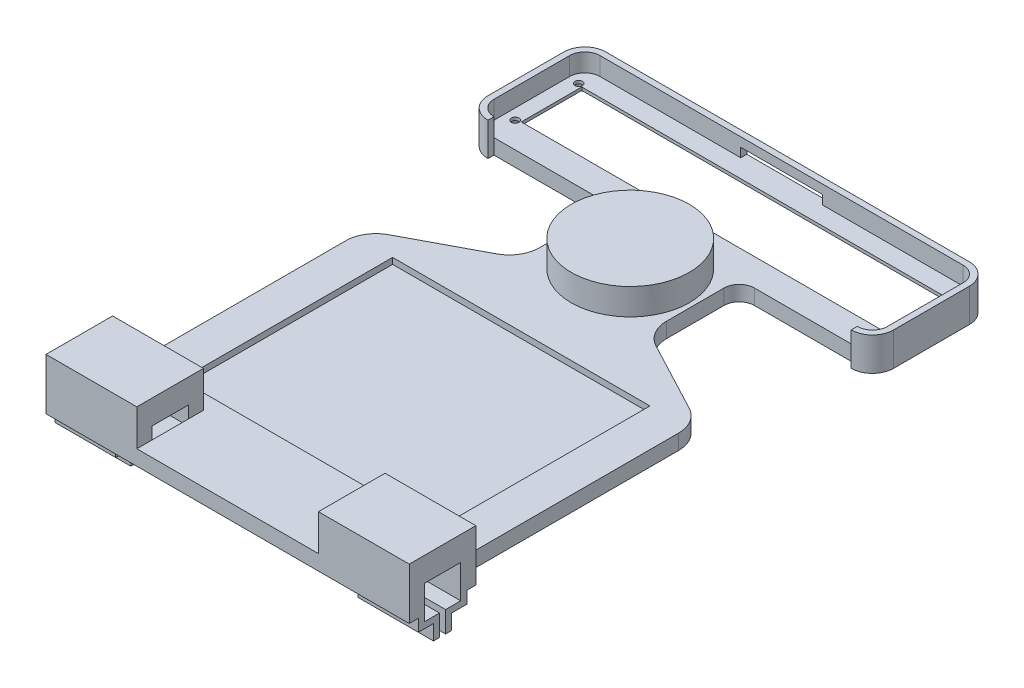
from build123d import *

# Parameters (mm, degrees)
BOSS_EXTRUDE1_DEPTH      = 2.5
SKETCH2_W                = 20
SKETCH2_H                = 12
CUT_EXTRUDE1_DEPTH       = 3
BOSS_EXTRUDE3_DEPTH      = 6
BOSS_EXTRUDE3_DEPTH_BACK = 5
BOSS_EXTRUDE4_DEPTH      = 20
BOSS_EXTRUDE5_DEPTH      = 20
SKETCH14_R               = 1.5
CUT_EXTRUDE6_DEPTH       = 178
SKETCH11_W               = 27
SKETCH11_H               = 3
CUT_EXTRUDE7_DEPTH       = 10
SKETCH15_R               = 1.25
SKETCH15_W               = 120
SKETCH15_H               = 20
CUT_EXTRUDE8_DEPTH       = 12
SKETCH15_3_R             = 1.25
SKETCH15_3_W             = 120
SKETCH15_3_H             = 20
CUT_EXTRUDE9_DEPTH       = 4
SKETCH17_W               = 30
SKETCH17_H               = 22
BOSS_EXTRUDE6_DEPTH      = 7
SKETCH18_W               = 12
SKETCH18_H               = 6
CUT_EXTRUDE11_DEPTH      = 30
SKETCH19_W               = 12
SKETCH19_H               = 6
CUT_EXTRUDE12_DEPTH      = 30
SKETCH16_W               = 85
SKETCH16_H               = 70
CUT_EXTRUDE13_DEPTH      = 2
SKETCH20_R               = 19.5
BOSS_EXTRUDE7_DEPTH      = 13.7
FILLET1_R                = 10
FILLET2_R                = 5
SKETCH21_W               = 30
SKETCH21_H               = 22
BOSS_EXTRUDE8_DEPTH      = 5


with BuildPart() as part:
    # Sketch1 → Boss-Extrude1 (new body, symmetric)
    with BuildSketch(Plane(origin=(0, 0, 0), x_dir=(1, 0, 0), z_dir=(0, 1, 0))):
        with BuildLine():
            Line((-21, 56.5), (-21, 26.5))
            Line((-21, 26.5), (-55, 8.5))
            Line((-55, 8.5), (-55, -69.5))
            Line((-55, -69.5), (-60, -69.5))
            Line((-60, -69.5), (-60, -91.5))
            Line((-60, -91.5), (60, -91.5))
            Line((60, -91.5), (60, -69.5))
            Line((60, -69.5), (55, -69.5))
            Line((55, -69.5), (55, 8.5))
            Line((55, 8.5), (21, 26.5))
            Line((21, 26.5), (21, 56.5))
            Line((21, 56.5), (60, 56.5))
            ThreePointArc((60, 56.5), (63.535533906, 57.964466094), (65, 61.5))
            Line((65, 61.5), (65, 86.5))
            ThreePointArc((65, 86.5), (63.535533906, 90.035533906), (60, 91.5))
            Line((60, 91.5), (-60, 91.5))
            ThreePointArc((-60, 91.5), (-63.535533906, 90.035533906), (-65, 86.5))
            Line((-65, 86.5), (-65, 61.5))
            ThreePointArc((-65, 61.5), (-63.535533906, 57.964466094), (-60, 56.5))
            Line((-60, 56.5), (-21, 56.5))
        make_face()
    extrude(amount=BOSS_EXTRUDE1_DEPTH, both=True)

    # Sketch2 → Cut-Extrude1 (cut)
    with BuildSketch(Plane.XZ.offset(2.5)):
        with Locations((-50, 80.5)):
            Rectangle(SKETCH2_W, SKETCH2_H)
        with Locations((50, 80.5)):
            Rectangle(SKETCH2_W, SKETCH2_H)
    extrude(amount=-CUT_EXTRUDE1_DEPTH, mode=Mode.SUBTRACT)

    # Sketch5 → Boss-Extrude3 (add, two sides)
    with BuildSketch(Plane(origin=(0, 2.5, 0), x_dir=(1, 0, 0), z_dir=(0, 1, 0))) as boss_extrude3_sk:
        with BuildLine():
            Line((-60, 56.5), (-60, 54.5))
            ThreePointArc((-60, 54.5), (-64.949747468, 56.550252532), (-67, 61.5))
            Line((-67, 61.5), (-67, 86.5))
            ThreePointArc((-67, 86.5), (-64.949747468, 91.449747468), (-60, 93.5))
            Line((-60, 93.5), (60, 93.5))
            ThreePointArc((60, 93.5), (64.949747468, 91.449747468), (67, 86.5))
            Line((67, 86.5), (67, 61.5))
            ThreePointArc((67, 61.5), (64.949747468, 56.550252532), (60, 54.5))
            Line((60, 54.5), (60, 56.5))
            ThreePointArc((60, 56.5), (63.535533906, 57.964466094), (65, 61.5))
            Line((65, 61.5), (65, 86.5))
            ThreePointArc((65, 86.5), (63.535533906, 90.035533906), (60, 91.5))
            Line((60, 91.5), (-60, 91.5))
            ThreePointArc((-60, 91.5), (-63.535533906, 90.035533906), (-65, 86.5))
            Line((-65, 86.5), (-65, 61.5))
            ThreePointArc((-65, 61.5), (-63.535533906, 57.964466094), (-60, 56.5))
        make_face()
    extrude(amount=BOSS_EXTRUDE3_DEPTH)
    extrude(boss_extrude3_sk.sketch, amount=-BOSS_EXTRUDE3_DEPTH_BACK)

    # Sketch12 → Boss-Extrude4 (add)
    with BuildSketch(Plane.ZY.offset(60)):
        Polygon((74.5, -2.5), (74.5, -4.5), (79.5, -4.5), (79.5, -11.5), (77.5, -11.5), (77.5, -6.5), (72.5, -6.5), (72.5, -4.5), (72.5, -2.5), align=None)
        Polygon((81.5, -11.5), (83.5, -11.5), (83.5, -6.5), (88.5, -6.5), (88.5, -4.5), (88.5, -2.5), (86.5, -2.5), (86.5, -4.5), (81.5, -4.5), align=None)
    extrude(amount=-BOSS_EXTRUDE4_DEPTH)

    # Sketch13 → Boss-Extrude5 (add)
    with BuildSketch(Plane(origin=(60, 0, 0), x_dir=(0, 0, -1), z_dir=(1, 0, 0))):
        Polygon((-86.5, -2.5), (-86.5, -4.5), (-81.5, -4.5), (-81.5, -11.5), (-83.5, -11.5), (-83.5, -6.5), (-88.5, -6.5), (-88.5, -2.5), align=None)
        Polygon((-79.5, -11.5), (-77.5, -11.5), (-77.5, -6.5), (-72.5, -6.5), (-72.5, -2.5), (-74.5, -2.5), (-74.5, -4.5), (-79.5, -4.5), align=None)
    extrude(amount=-BOSS_EXTRUDE5_DEPTH)

    # Sketch14 → Cut-Extrude6 (cut, through all)
    with BuildSketch(Plane.XY.offset(83.5)):
        with Locations((45, -8.5)):
            Circle(SKETCH14_R)
        with Locations((55, -8.5)):
            Circle(SKETCH14_R)
        with Locations((-55, -8.5)):
            Circle(SKETCH14_R)
        with Locations((-45, -8.5)):
            Circle(SKETCH14_R)
    extrude(amount=-CUT_EXTRUDE6_DEPTH, mode=Mode.SUBTRACT)

    # Sketch11 → Cut-Extrude7 (cut)
    with BuildSketch(Plane(origin=(0, 0, -93.5), x_dir=(-1, 0, 0), z_dir=(0, 0, -1))):
        with Locations((0, 4)):
            Rectangle(SKETCH11_W, SKETCH11_H)
    extrude(amount=-CUT_EXTRUDE7_DEPTH, mode=Mode.SUBTRACT)

    # Sketch15 → Cut-Extrude8 (cut, through all)
    with BuildSketch(Plane.XZ.offset(2.5)):
        with Locations((-61.5, -65)):
            Circle(SKETCH15_R)
        with Locations((61.5, -65)):
            Circle(SKETCH15_R)
        with Locations((61.5, -86)):
            Circle(SKETCH15_R)
        with Locations((-61.5, -86)):
            Circle(SKETCH15_R)
        with Locations((0, -75.5)):
            Rectangle(SKETCH15_W, SKETCH15_H)
    extrude(amount=-CUT_EXTRUDE8_DEPTH, mode=Mode.SUBTRACT)

    # Sketch15_3 → Cut-Extrude9 (cut)
    with BuildSketch(Plane.XZ.offset(2.5)):
        with BuildLine():
            Line((-63, -61.5), (63, -61.5))
            ThreePointArc((63, -61.5), (64.414213562, -62.085786438), (65, -63.5))
            Line((65, -63.5), (65, -87.5))
            ThreePointArc((65, -87.5), (64.414213562, -88.914213562), (63, -89.5))
            Line((63, -89.5), (-63, -89.5))
            ThreePointArc((-63, -89.5), (-64.414213562, -88.914213562), (-65, -87.5))
            Line((-65, -87.5), (-65, -63.5))
            ThreePointArc((-65, -63.5), (-64.414213562, -62.085786438), (-63, -61.5))
        make_face()
        with Locations((61.5, -65)):
            Circle(SKETCH15_3_R, mode=Mode.SUBTRACT)
        with Locations((-61.5, -65)):
            Circle(SKETCH15_3_R, mode=Mode.SUBTRACT)
        with Locations((61.5, -86)):
            Circle(SKETCH15_3_R, mode=Mode.SUBTRACT)
        with Locations((-61.5, -86)):
            Circle(SKETCH15_3_R, mode=Mode.SUBTRACT)
        with Locations((0, -75.5)):
            Rectangle(SKETCH15_3_W, SKETCH15_3_H, mode=Mode.SUBTRACT)
    extrude(amount=-CUT_EXTRUDE9_DEPTH, mode=Mode.SUBTRACT)

    # Sketch17 → Boss-Extrude6 (add)
    with BuildSketch(Plane(origin=(0, 2.5, 0), x_dir=(1, 0, 0), z_dir=(0, 1, 0))):
        with Locations((-45, -80.5)):
            Rectangle(SKETCH17_W, SKETCH17_H)
        with Locations((45, -80.5)):
            Rectangle(SKETCH17_W, SKETCH17_H)
    extrude(amount=BOSS_EXTRUDE6_DEPTH)

    # Sketch18 → Cut-Extrude11 (cut)
    with BuildSketch(Plane(origin=(60, 0, 0), x_dir=(0, 0, -1), z_dir=(1, 0, 0))):
        with Locations((-80.5, 3.5)):
            Rectangle(SKETCH18_W, SKETCH18_H)
    extrude(amount=-CUT_EXTRUDE11_DEPTH, mode=Mode.SUBTRACT)

    # Sketch19 → Cut-Extrude12 (cut)
    with BuildSketch(Plane.ZY.offset(60)):
        with Locations((80.5, 3.5)):
            Rectangle(SKETCH19_W, SKETCH19_H)
    extrude(amount=-CUT_EXTRUDE12_DEPTH, mode=Mode.SUBTRACT)

    # Sketch16 → Cut-Extrude13 (cut)
    with BuildSketch(Plane(origin=(0, 2.5, 0), x_dir=(1, 0, 0), z_dir=(0, 1, 0))):
        with Locations((0, -29.5)):
            Rectangle(SKETCH16_W, SKETCH16_H)
    extrude(amount=-CUT_EXTRUDE13_DEPTH, mode=Mode.SUBTRACT)

    # Sketch20 → Boss-Extrude7 (add)
    with BuildSketch(Plane.XZ.offset(2.5)):
        with Locations((0, -41.5)):
            Circle(SKETCH20_R)
    extrude(amount=-BOSS_EXTRUDE7_DEPTH)

    # Fillet1
    fillet1_edges = [part.edges().sort_by_distance(p)[0] for p in [
        (21, 0, -26.5),
        (55, 0, -8.5),
        (-55, 0, -8.5),
        (-21, 0, -26.5),
    ]]
    fillet(fillet1_edges, radius=FILLET1_R)

    # Fillet2
    fillet2_edges = [part.edges().sort_by_distance(p)[0] for p in [
        (21, 0, -56.5),
        (-21, 0, -56.5),
    ]]
    fillet(fillet2_edges, radius=FILLET2_R)

    # Sketch21 → Boss-Extrude8 (add)
    with BuildSketch(Plane(origin=(0, 9.5, 0), x_dir=(1, 0, 0), z_dir=(0, 1, 0))):
        with Locations((45, -80.5)):
            Rectangle(SKETCH21_W, SKETCH21_H)
        with Locations((-45, -80.5)):
            Rectangle(SKETCH21_W, SKETCH21_H)
    extrude(amount=BOSS_EXTRUDE8_DEPTH)


solid = part.part
